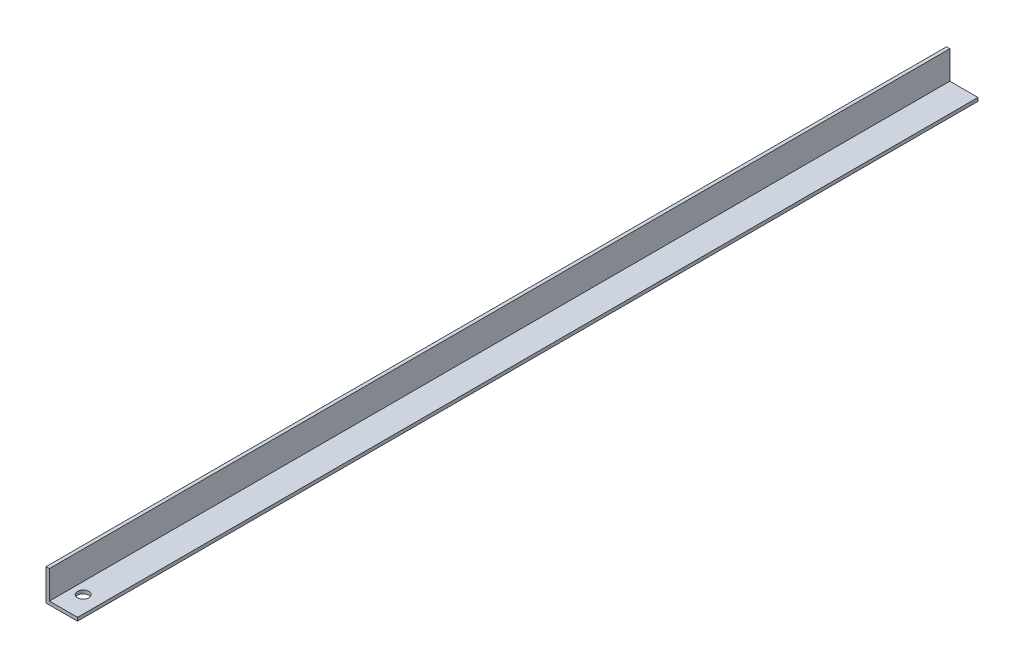
from build123d import *

# Parameters (mm, degrees)
EXTRUDE_1_DEPTH     = 800
SKETCH_2_R          = 5
CUT_EXTRUDE_1_DEPTH = 10


with BuildPart() as part:
    # Эскиз1 → Вытянуть-Тонкостенный1 (new body)
    with BuildSketch(Plane.XY):
        Polygon((0, 25), (0, 0), (25, 0), (25, -3), (-3, -3), (-3, 25), align=None)
    extrude(amount=EXTRUDE_1_DEPTH)

    # Эскиз2 → Вырез-Вытянуть1 (cut)
    with BuildSketch(Plane.XZ.offset(3)):
        with Locations((10, 780)):
            Circle(SKETCH_2_R)
    extrude(amount=-CUT_EXTRUDE_1_DEPTH, mode=Mode.SUBTRACT)


solid = part.part
